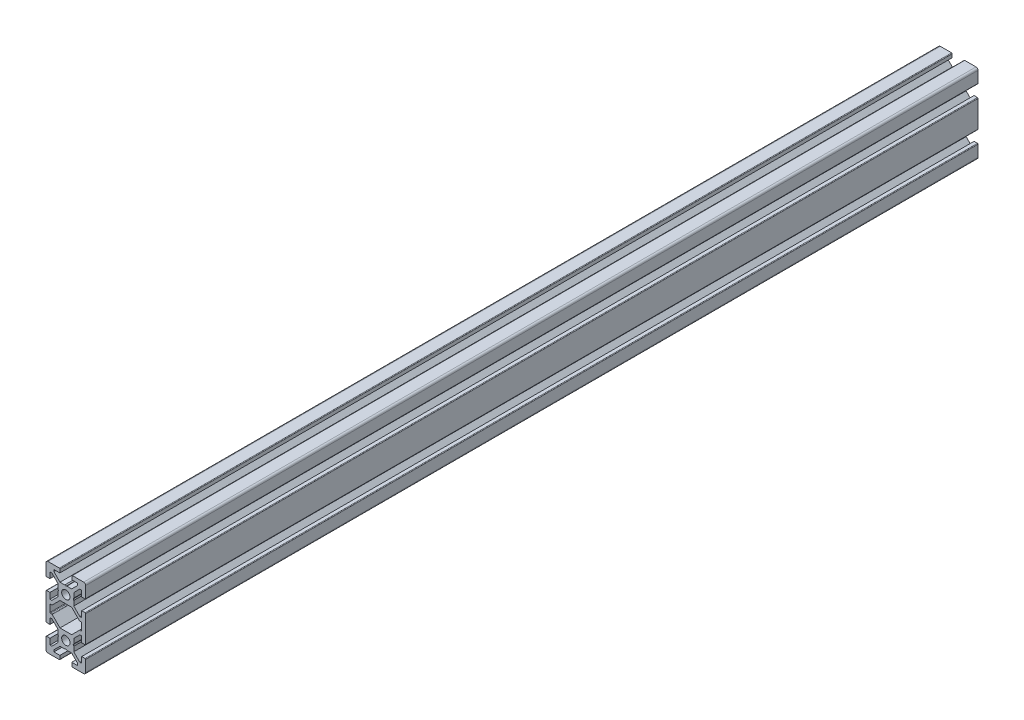
from build123d import *

# Parameters (mm, degrees)
SKETCH1_R           = 2.0999999
BOSS_EXTRUDE1_DEPTH = 450


with BuildPart() as part:
    # Sketch1 → Boss-Extrude1 (new body)
    with BuildSketch(Plane(origin=(0, 0, 0), x_dir=(-1, 0, 0), z_dir=(0, 0, -1))):
        with BuildLine():
            Line((10, -19), (10, -13.3000005))
            ThreePointArc((10, -13.3000005), (9.912132034, -13.087868466), (9.7, -13.0000005))
            Line((9.7, -13.0000005), (7.999996324, -13.0000005))
            Line((7.999996324, -13.0000005), (7.999996324, -16.0000005))
            Line((7.999996324, -16.0000005), (7.0606365, -16.0000005))
            Line((7.0606365, -16.0000005), (4, -12.9393575))
            Line((4, -12.9393575), (4, -10.519615742))
            Line((4, -10.519615742), (3.7, -10.0000005))
            Line((3.7, -10.0000005), (4, -9.480385258))
            Line((4, -9.480385258), (4, -7.0606688))
            Line((4, -7.0606688), (7.06066257, -4.000000504))
            Line((7.06066257, -4.000000504), (7.999996324, -4.000000504))
            Line((7.999996324, -4.000000504), (7.999996324, -7.0000005))
            Line((7.999996324, -7.0000005), (9.7, -7.0000005))
            ThreePointArc((9.7, -7.0000005), (9.912132034, -6.912132534), (10, -6.7000005))
            Line((10, -6.7000005), (10, 6.7))
            ThreePointArc((10, 6.7), (9.912132034, 6.912132034), (9.7, 7))
            Line((9.7, 7), (7.999996324, 7))
            Line((7.999996324, 7), (7.999996324, 4))
            Line((7.999996324, 4), (7.060659, 4))
            Line((7.060659, 4), (4, 7.06066))
            Line((4, 7.06066), (4, 9.480384758))
            Line((4, 9.480384758), (3.7, 10))
            Line((3.7, 10), (4, 10.519615242))
            Line((4, 10.519615242), (4, 12.9393565))
            Line((4, 12.9393565), (7.060642, 16))
            Line((7.060642, 16), (7.999996324, 16))
            Line((7.999996324, 16), (7.999996324, 13))
            Line((7.999996324, 13), (9.7, 13))
            ThreePointArc((9.7, 13), (9.912132034, 13.087867966), (10, 13.3))
            Line((10, 13.3), (10, 19))
            ThreePointArc((10, 19), (9.707106781, 19.707106781), (9, 20))
            Line((9, 20), (3.3, 20))
            ThreePointArc((3.3, 20), (3.087867966, 19.912132034), (3, 19.7))
            Line((3, 19.7), (3, 17.999998284))
            Line((3, 17.999998284), (5.999998141, 17.999998284))
            Line((5.999998141, 17.999998284), (5.999998141, 17.060676141))
            Line((5.999998141, 17.060676141), (2.939333284, 13.999998284))
            Line((2.939333284, 13.999998284), (0.519636909, 13.999998284))
            Line((0.519636909, 13.999998284), (-1.716e-06, 13.699984784))
            Line((-1.716e-06, 13.699984784), (-0.519640341, 13.999998284))
            Line((-0.519640341, 13.999998284), (-2.939355716, 13.999998284))
            Line((-2.939355716, 13.999998284), (-6.000001716, 17.060658034))
            Line((-6.000001716, 17.060658034), (-6.000001716, 17.999998284))
            Line((-6.000001716, 17.999998284), (-3, 17.999998284))
            Line((-3, 17.999998284), (-3, 19.7))
            ThreePointArc((-3, 19.7), (-3.087867966, 19.912132034), (-3.3, 20))
            Line((-3.3, 20), (-9, 20))
            ThreePointArc((-9, 20), (-9.707106781, 19.707106781), (-10, 19))
            Line((-10, 19), (-10, 13.3))
            ThreePointArc((-10, 13.3), (-9.912132034, 13.087867966), (-9.7, 13))
            Line((-9.7, 13), (-8.000003676, 13))
            Line((-8.000003676, 13), (-8.000003676, 16))
            Line((-8.000003676, 16), (-7.060661, 16))
            Line((-7.060661, 16), (-4, 12.93933675))
            Line((-4, 12.93933675), (-4, 10.519615242))
            Line((-4, 10.519615242), (-3.7, 10))
            Line((-3.7, 10), (-4, 9.480384758))
            Line((-4, 9.480384758), (-4, 7.06068075))
            Line((-4, 7.06068075), (-7.060678, 4))
            Line((-7.060678, 4), (-8.000003676, 4))
            Line((-8.000003676, 4), (-8.000003676, 7))
            Line((-8.000003676, 7), (-9.7, 7))
            ThreePointArc((-9.7, 7), (-9.912132034, 6.912132034), (-10, 6.7))
            Line((-10, 6.7), (-10, -6.7000005))
            ThreePointArc((-10, -6.7000005), (-9.912132034, -6.912132534), (-9.7, -7.0000005))
            Line((-9.7, -7.0000005), (-8.000003676, -7.0000005))
            Line((-8.000003676, -7.0000005), (-8.000003676, -4.000000504))
            Line((-8.000003676, -4.000000504), (-7.06068236, -4.000000504))
            Line((-7.06068236, -4.000000504), (-4, -7.06068365))
            Line((-4, -7.06068365), (-4, -9.480385258))
            Line((-4, -9.480385258), (-3.7, -10.0000005))
            Line((-3.7, -10.0000005), (-4, -10.519615742))
            Line((-4, -10.519615742), (-4, -12.93934215))
            Line((-4, -12.93934215), (-7.06065685, -16.0000005))
            Line((-7.06065685, -16.0000005), (-8.000003676, -16.0000005))
            Line((-8.000003676, -16.0000005), (-8.000003676, -13.0000005))
            Line((-8.000003676, -13.0000005), (-9.7, -13.0000005))
            ThreePointArc((-9.7, -13.0000005), (-9.912132034, -13.087868466), (-10, -13.3000005))
            Line((-10, -13.3000005), (-10, -19))
            ThreePointArc((-10, -19), (-9.707106781, -19.707106781), (-9, -20))
            Line((-9, -20), (-3.3, -20))
            ThreePointArc((-3.3, -20), (-3.087867966, -19.912132034), (-3, -19.7))
            Line((-3, -19.7), (-3, -18.000001716))
            Line((-3, -18.000001716), (-6.000001716, -18.000001716))
            Line((-6.000001716, -18.000001716), (-6.000001716, -17.060664516))
            Line((-6.000001716, -17.060664516), (-2.939338216, -14.000001716))
            Line((-2.939338216, -14.000001716), (-0.519616958, -14.000001716))
            Line((-0.519616958, -14.000001716), (-1.716e-06, -13.700001716))
            Line((-1.716e-06, -13.700001716), (0.519613526, -14.000001716))
            Line((0.519613526, -14.000001716), (2.939316284, -14.000001716))
            Line((2.939316284, -14.000001716), (5.999998141, -17.060684359))
            Line((5.999998141, -17.060684359), (5.999998141, -18.000001716))
            Line((5.999998141, -18.000001716), (3, -18.000001716))
            Line((3, -18.000001716), (3, -19.7))
            ThreePointArc((3, -19.7), (3.087867966, -19.912132034), (3.3, -20))
            Line((3.3, -20), (9, -20))
            ThreePointArc((9, -20), (9.707106781, -19.707106781), (10, -19))
        make_face()
        with Locations((0, -10.0000005)):
            Circle(SKETCH1_R, mode=Mode.SUBTRACT)
        with Locations((0, 10)):
            Circle(SKETCH1_R, mode=Mode.SUBTRACT)
        with BuildLine():
            Line((7.999996324, 1.699995824), (7.999996324, -1.700003926))
            ThreePointArc((7.999996324, -1.700003926), (7.912128359, -1.91213596), (7.699996324, -2.000003926))
            Line((7.699996324, -2.000003926), (7.063600862, -2.000003926))
            ThreePointArc((7.063600862, -2.000003926), (6.94879664, -2.022827662), (6.85147763, -2.08786567))
            Line((6.85147763, -2.08786567), (2.939331324, -6.000003676))
            Line((2.939331324, -6.000003676), (-2.939335626, -6.000003676))
            Line((-2.939335626, -6.000003676), (-6.85148297, -2.087865332))
            ThreePointArc((-6.85148297, -2.087865332), (-6.948803597, -2.022827887), (-7.063608826, -2.000003926))
            Line((-7.063608826, -2.000003926), (-7.700003676, -2.000003926))
            ThreePointArc((-7.700003676, -2.000003926), (-7.91213571, -1.91213596), (-8.000003676, -1.700003926))
            Line((-8.000003676, -1.700003926), (-8.000003676, 1.699995824))
            ThreePointArc((-8.000003676, 1.699995824), (-7.91213571, 1.912127859), (-7.700003676, 1.999995824))
            Line((-7.700003676, 1.999995824), (-7.063603126, 1.999995824))
            ThreePointArc((-7.063603126, 1.999995824), (-6.948797876, 2.022820045), (-6.851477822, 2.087858478))
            Line((-6.851477822, 2.087858478), (-2.939339176, 5.999996324))
            Line((-2.939339176, 5.999996324), (2.939335324, 5.999996324))
            Line((2.939335324, 5.999996324), (6.85147158, 2.087857193))
            ThreePointArc((6.85147158, 2.087857193), (6.948790922, 2.02281871), (7.063595862, 1.999995824))
            Line((7.063595862, 1.999995824), (7.699996324, 1.999995824))
            ThreePointArc((7.699996324, 1.999995824), (7.912128359, 1.912127859), (7.999996324, 1.699995824))
        make_face(mode=Mode.SUBTRACT)
    extrude(amount=BOSS_EXTRUDE1_DEPTH)


solid = part.part
